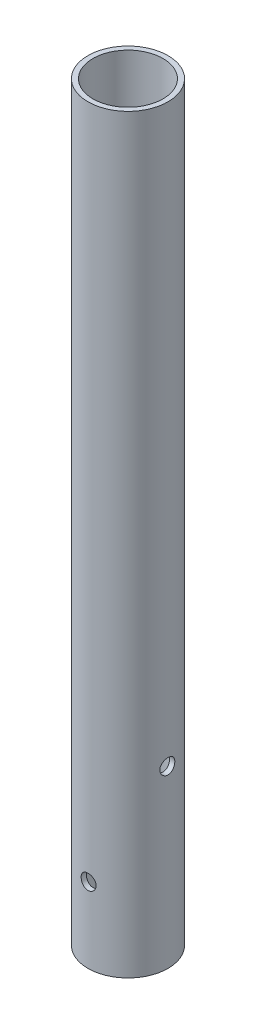
from build123d import *

# Parameters (mm, degrees)
SKETCH_1_R               = 8
SKETCH_1_R_2             = 7
EXTRUDE_1_DEPTH          = 150
SKETCH_2_R               = 1.5
CUT_EXTRUDE_1_DEPTH      = 9
CUT_EXTRUDE_1_DEPTH_BACK = 9
SKETCH_4_R               = 1.5
CUT_EXTRUDE_2_DEPTH      = 9.0000001
CUT_EXTRUDE_2_DEPTH_BACK = 9.0000001


with BuildPart() as part:
    # 草图1 → 凸台-拉伸1 (new body)
    with BuildSketch(Plane(origin=(0, 0, 0), x_dir=(1, 0, 0), z_dir=(0, 1, 0))):
        Circle(SKETCH_1_R)
        Circle(SKETCH_1_R_2, mode=Mode.SUBTRACT)
    extrude(amount=EXTRUDE_1_DEPTH)

    # 草图2 → 切除-拉伸1 (cut, two sides)
    with BuildSketch(Plane.XY) as cut_extrude_1_sk:
        with Locations((0, 15)):
            Circle(SKETCH_2_R)
    extrude(amount=CUT_EXTRUDE_1_DEPTH, mode=Mode.SUBTRACT)
    extrude(cut_extrude_1_sk.sketch, amount=-CUT_EXTRUDE_1_DEPTH_BACK, mode=Mode.SUBTRACT)

    # 草图4 → 切除-拉伸2 (cut, two sides)
    with BuildSketch(Plane(origin=(0, 0, 0), x_dir=(0, 0, -1), z_dir=(1, 0, 0))) as cut_extrude_2_sk:
        with Locations((0, 35)):
            Circle(SKETCH_4_R)
    extrude(amount=CUT_EXTRUDE_2_DEPTH, mode=Mode.SUBTRACT)
    extrude(cut_extrude_2_sk.sketch, amount=-CUT_EXTRUDE_2_DEPTH_BACK, mode=Mode.SUBTRACT)


solid = part.part
